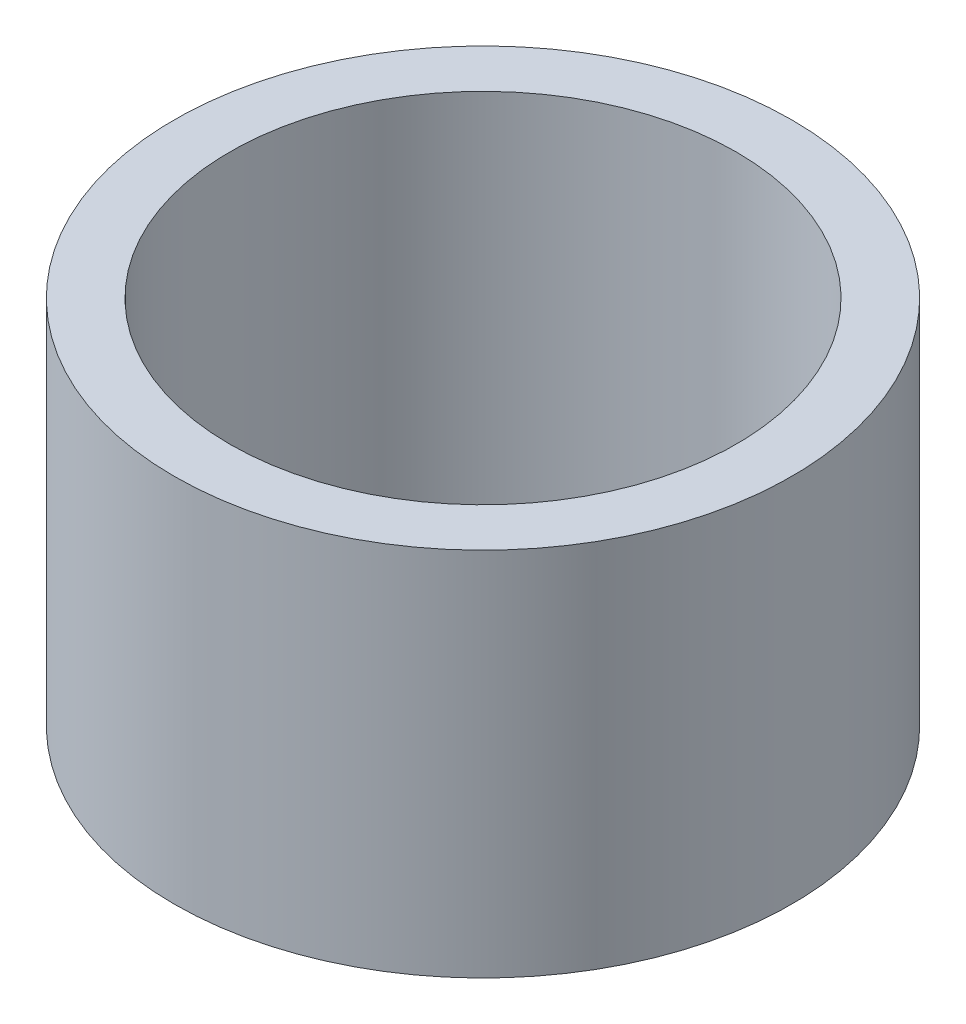
from build123d import *

# Parameters (mm, degrees)
CROQUIS1_R              = 2.5
SALIENTE_EXTRUIR1_DEPTH = 3
CROQUIS2_R              = 2.05
CORTAR_EXTRUIR1_DEPTH   = 5


with BuildPart() as part:
    # Croquis1 → Saliente-Extruir1 (new body)
    with BuildSketch(Plane(origin=(0, 0, 0), x_dir=(1, 0, 0), z_dir=(0, 1, 0))):
        Circle(CROQUIS1_R)
    extrude(amount=SALIENTE_EXTRUIR1_DEPTH)

    # Croquis2 → Cortar-Extruir1 (cut)
    with BuildSketch(Plane(origin=(0, 3, 0), x_dir=(1, 0, 0), z_dir=(0, 1, 0))):
        Circle(CROQUIS2_R)
    extrude(amount=-CORTAR_EXTRUIR1_DEPTH, mode=Mode.SUBTRACT)


solid = part.part
